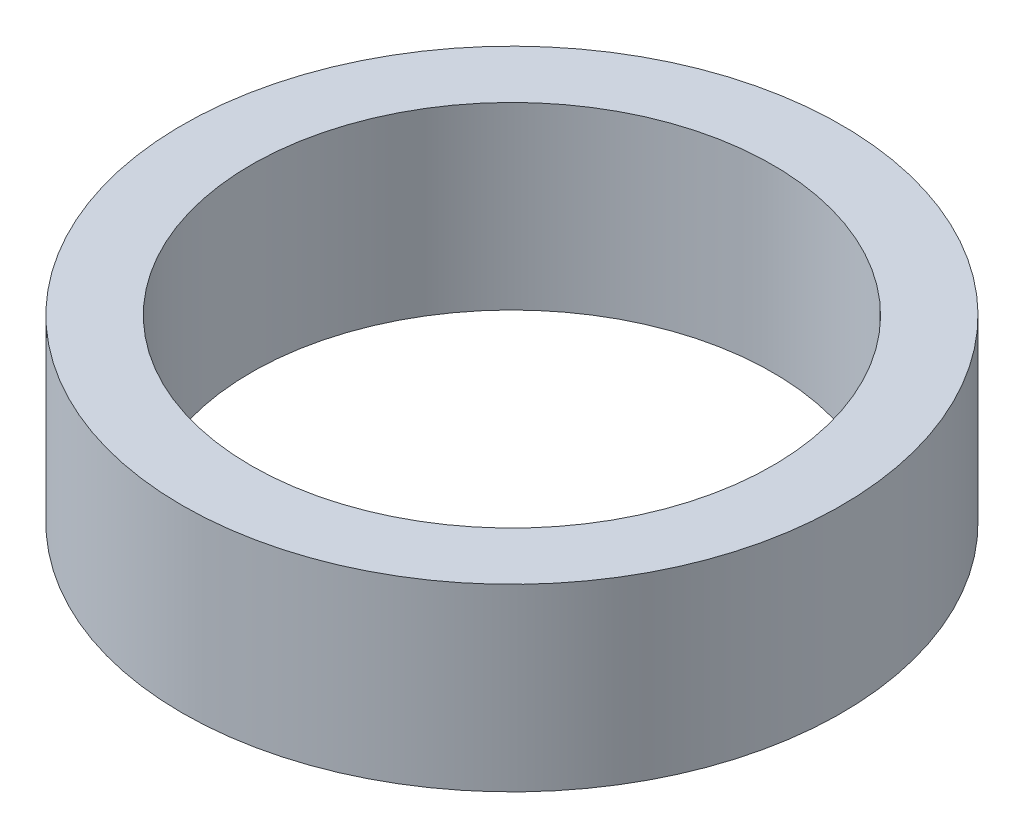
from build123d import *

# Parameters (mm, degrees)
SKETCH_1_R      = 5.5
SKETCH_1_R_2    = 4.35
EXTRUDE_1_DEPTH = 3


with BuildPart() as part:
    # 草图1 → 凸台-拉伸1 (new body)
    with BuildSketch(Plane(origin=(0, 0, 0), x_dir=(1, 0, 0), z_dir=(0, 1, 0))):
        with Locations((-10.099938602, 4.898877949)):
            Circle(SKETCH_1_R)
        with Locations((-10.099938602, 4.898877949)):
            Circle(SKETCH_1_R_2, mode=Mode.SUBTRACT)
    extrude(amount=EXTRUDE_1_DEPTH)


solid = part.part
